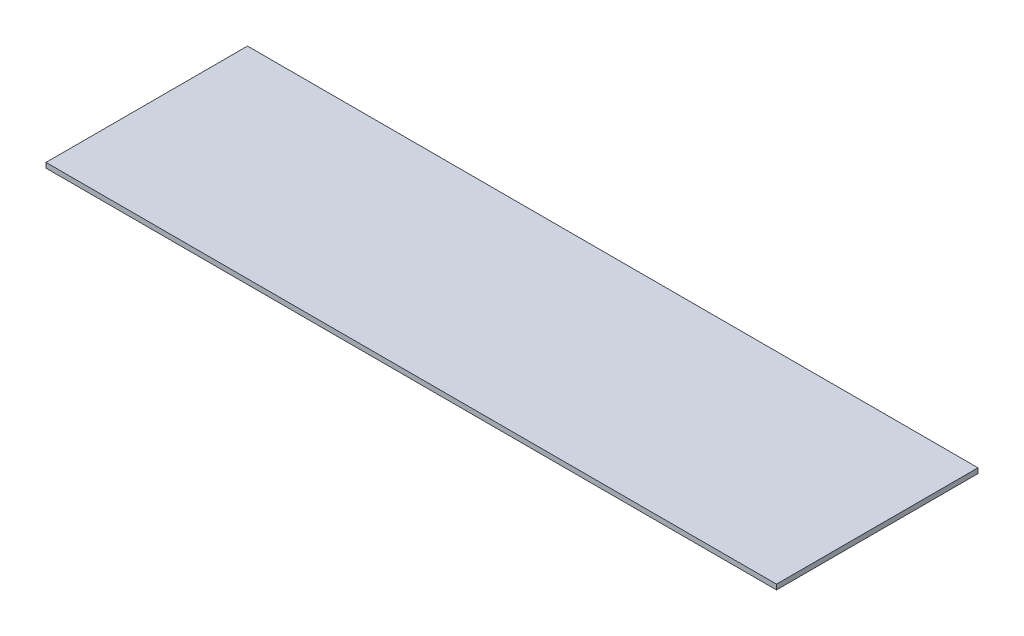
from build123d import *

# Parameters (mm, degrees)
SKETCH1_W           = 290
SKETCH1_H           = 80
BOSS_EXTRUDE1_DEPTH = 2


with BuildPart() as part:
    # Sketch1 → Boss-Extrude1 (new body)
    with BuildSketch(Plane(origin=(0, 0, 0), x_dir=(1, 0, 0), z_dir=(0, 1, 0))):
        Rectangle(SKETCH1_W, SKETCH1_H)
    extrude(amount=BOSS_EXTRUDE1_DEPTH)


solid = part.part
